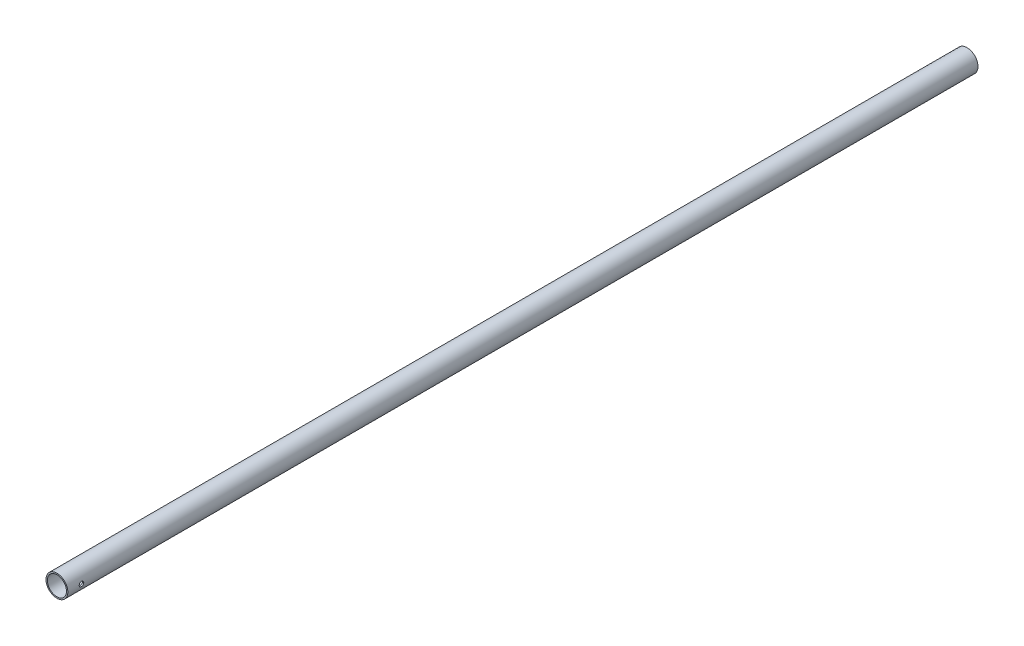
from build123d import *

# Parameters (mm, degrees)
SZKIC1_R                              = 24
SZKIC1_R_2                            = 21
DODANIE_WYCI_GNI_CIE1_DEPTH           = 2000
OTWORY_USTALAJ_CE_10_0MM2_D           = 10
OTWORY_USTALAJ_CE_10_0MM2_CSINK_D     = 10.05
OTWORY_USTALAJ_CE_10_0MM2_CSINK_ANGLE = 90


with BuildPart() as part:
    # Szkic1 → Dodanie-wyciągnięcie1 (new body)
    with BuildSketch(Plane.XY):
        Circle(SZKIC1_R)
        Circle(SZKIC1_R_2, mode=Mode.SUBTRACT)
    extrude(amount=DODANIE_WYCI_GNI_CIE1_DEPTH)

    # Otwory ustalające Ø10.0mm2 (through all)
    with Locations(Plane(origin=(24, 0, 1970), x_dir=(0, 1, 0), z_dir=(1, 0, 0))):
        with Locations((0, 0)):
            CounterSinkHole(OTWORY_USTALAJ_CE_10_0MM2_D / 2, OTWORY_USTALAJ_CE_10_0MM2_CSINK_D / 2, counter_sink_angle=OTWORY_USTALAJ_CE_10_0MM2_CSINK_ANGLE)


solid = part.part
